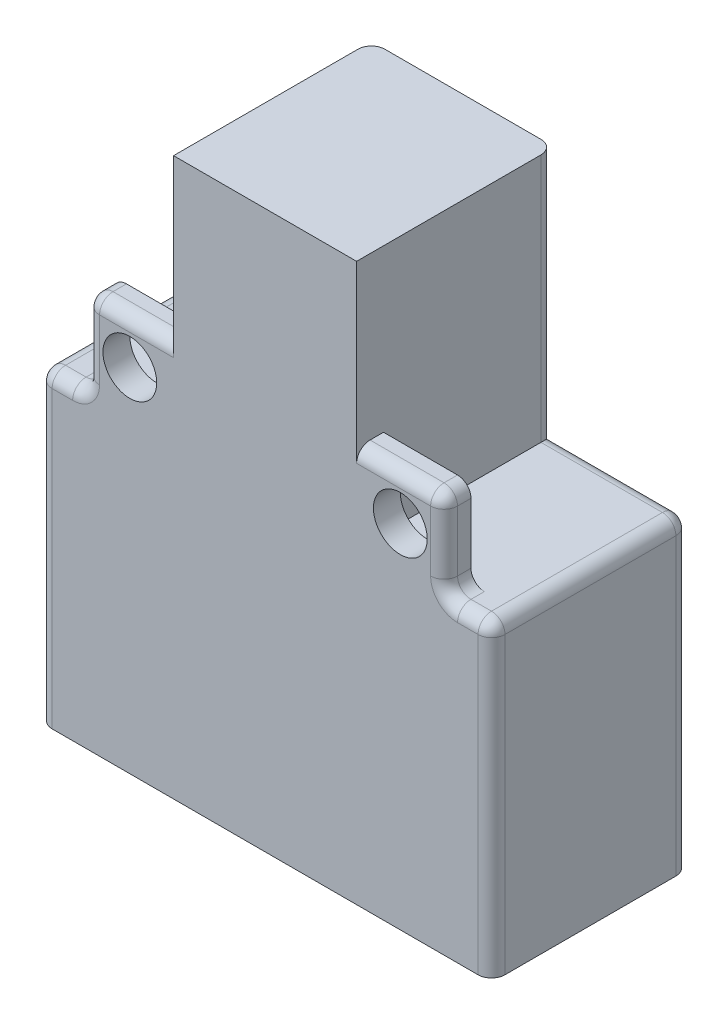
from build123d import *

# Parameters (mm, degrees)
SKETCH1_W           = 33.65
SKETCH1_H           = 14.7
BOSS_EXTRUDE1_DEPTH = 22.9
SKETCH2_W           = 13.6
SKETCH2_H           = 14.7
BOSS_EXTRUDE2_DEPTH = 18.5
SKETCH3_W           = 6.5
SKETCH3_H           = 2
BOSS_EXTRUDE3_DEPTH = 6.5
SKETCH4_W           = 6.5
SKETCH4_H           = 2
BOSS_EXTRUDE4_DEPTH = 6.5
SKETCH5_R           = 1.996461688
CUT_EXTRUDE1_DEPTH  = 3.75
SKETCH6_R           = 2
CUT_EXTRUDE2_DEPTH  = 3.75
FILLET2_R           = 1
FILLET3_R           = 1


with BuildPart() as part:
    # Sketch1 → Boss-Extrude1 (new body)
    with BuildSketch(Plane(origin=(0, 0, 0), x_dir=(1, 0, 0), z_dir=(0, 1, 0))):
        with Locations((6.48576555, -0.615430622)):
            Rectangle(SKETCH1_W, SKETCH1_H)
    extrude(amount=BOSS_EXTRUDE1_DEPTH)

    # Sketch2 → Boss-Extrude2 (add)
    with BuildSketch(Plane(origin=(0, 22.9, 0), x_dir=(1, 0, 0), z_dir=(0, 1, 0))):
        with Locations((6.48576555, -0.615430622)):
            Rectangle(SKETCH2_W, SKETCH2_H)
    extrude(amount=BOSS_EXTRUDE2_DEPTH)

    # Sketch3 → Boss-Extrude3 (add)
    with BuildSketch(Plane(origin=(0, 22.9, 0), x_dir=(1, 0, 0), z_dir=(0, 1, 0))):
        with Locations((-3.56423445, -6.965430622)):
            Rectangle(SKETCH3_W, SKETCH3_H)
    extrude(amount=BOSS_EXTRUDE3_DEPTH)

    # Sketch4 → Boss-Extrude4 (add)
    with BuildSketch(Plane(origin=(0, 22.9, 0), x_dir=(1, 0, 0), z_dir=(0, 1, 0))):
        with Locations((16.53576555, -6.965430622)):
            Rectangle(SKETCH4_W, SKETCH4_H)
    extrude(amount=BOSS_EXTRUDE4_DEPTH)

    # Sketch5 → Cut-Extrude1 (cut, symmetric)
    with BuildSketch(Plane(origin=(0, 0, 5.965430622), x_dir=(-1, 0, 0), z_dir=(0, 0, -1))):
        with Locations((3.56423445, 26.15)):
            Circle(SKETCH5_R)
    extrude(amount=CUT_EXTRUDE1_DEPTH, both=True, mode=Mode.SUBTRACT)

    # Sketch6 → Cut-Extrude2 (cut, symmetric)
    with BuildSketch(Plane(origin=(0, 0, 5.965430622), x_dir=(-1, 0, 0), z_dir=(0, 0, -1))):
        with Locations((-16.53576555, 26.15)):
            Circle(SKETCH6_R)
    extrude(amount=CUT_EXTRUDE2_DEPTH, both=True, mode=Mode.SUBTRACT)

    # Fillet2
    fillet2_edges = [part.edges().sort_by_distance(p)[0] for p in [
        (23.31076555, 22.9, 0.615430622),
        (-6.81423445, 22.9, 6.965430622),
        (-6.81423445, 29.4, 6.965430622),
        (19.78576555, 22.9, 6.965430622),
        (19.78576555, 29.4, 6.965430622),
        (-10.33923445, 22.9, 0.615430622),
    ]]
    fillet(fillet2_edges, radius=FILLET2_R)

    # Fillet3
    fillet3_edges = [part.edges().sort_by_distance(p)[0] for p in [
        (-4.82673445, 22.9, -6.734569378),
        (-0.31423445, 32.15, -6.734569378),
        (13.28576555, 32.15, -6.734569378),
        (16.03576555, 29.4, 7.965430622),
        (19.78576555, 26.15, 7.965430622),
        (21.54826555, 22.9, 7.965430622),
        (17.79826555, 22.9, -6.734569378),
        (-6.81423445, 26.15, 7.965430622),
        (-8.57673445, 22.9, 7.965430622),
        (-3.06423445, 29.4, 7.965430622),
        (-10.33923445, 10.95, 7.965430622),
        (23.31076555, 10.95, 7.965430622),
        (23.017872331, 22.607106781, 7.965430622),
        (-10.046341231, 22.607106781, 7.965430622),
        (-6.521341231, 29.107106781, 7.965430622),
        (19.492872331, 29.107106781, 7.965430622),
        (-10.33923445, 10.95, -6.734569378),
        (23.31076555, 10.95, -6.734569378),
        (23.017872331, 22.607106781, -6.734569378),
        (-10.046341231, 22.607106781, -6.734569378),
        (20.078658769, 23.192893219, 7.965430622),
        (-7.107127669, 23.192893219, 7.965430622),
    ]]
    fillet(fillet3_edges, radius=FILLET3_R)


solid = part.part
